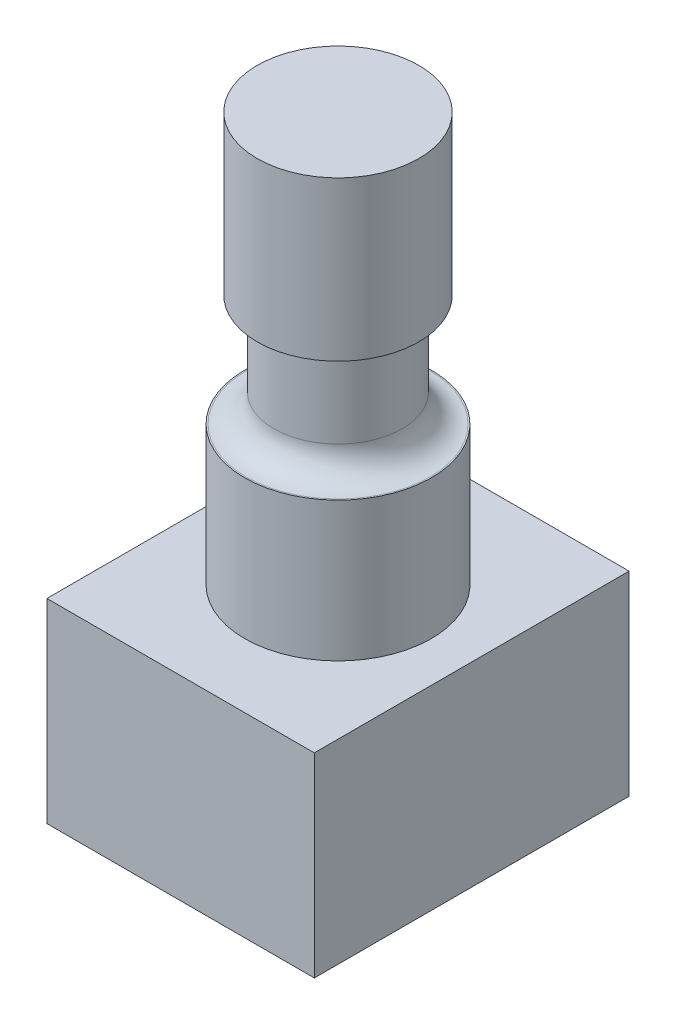
from build123d import *

# Parameters (mm, degrees)
SKETCH1_W           = 9.6
SKETCH1_H           = 11.3
BOSS_EXTRUDE1_DEPTH = 7
SKETCH2_R           = 3.35
BOSS_EXTRUDE2_DEPTH = 5
SKETCH3_R           = 2.3
BOSS_EXTRUDE3_DEPTH = 4
FILLET1_R           = 1
SKETCH4_R           = 2.9
BOSS_EXTRUDE4_DEPTH = 5.7


with BuildPart() as part:
    # Sketch1 → Boss-Extrude1 (new body)
    with BuildSketch(Plane(origin=(0, 0, 0), x_dir=(1, 0, 0), z_dir=(0, 1, 0))):
        Rectangle(SKETCH1_W, SKETCH1_H)
    extrude(amount=BOSS_EXTRUDE1_DEPTH)

    # Sketch2 → Boss-Extrude2 (add)
    with BuildSketch(Plane(origin=(0, 7, 0), x_dir=(1, 0, 0), z_dir=(0, 1, 0))):
        Circle(SKETCH2_R)
    extrude(amount=BOSS_EXTRUDE2_DEPTH)

    # Sketch3 → Boss-Extrude3 (add)
    with BuildSketch(Plane(origin=(0, 12, 0), x_dir=(1, 0, 0), z_dir=(0, 1, 0))):
        Circle(SKETCH3_R)
    extrude(amount=BOSS_EXTRUDE3_DEPTH)

    # Fillet1
    fillet1_edges = [part.edges().sort_by_distance(p)[0] for p in [
        (-2.3, 12, 0),
    ]]
    fillet(fillet1_edges, radius=FILLET1_R)

    # Sketch4 → Boss-Extrude4 (add)
    with BuildSketch(Plane(origin=(0, 16, 0), x_dir=(1, 0, 0), z_dir=(0, 1, 0))):
        Circle(SKETCH4_R)
    extrude(amount=BOSS_EXTRUDE4_DEPTH)


solid = part.part
